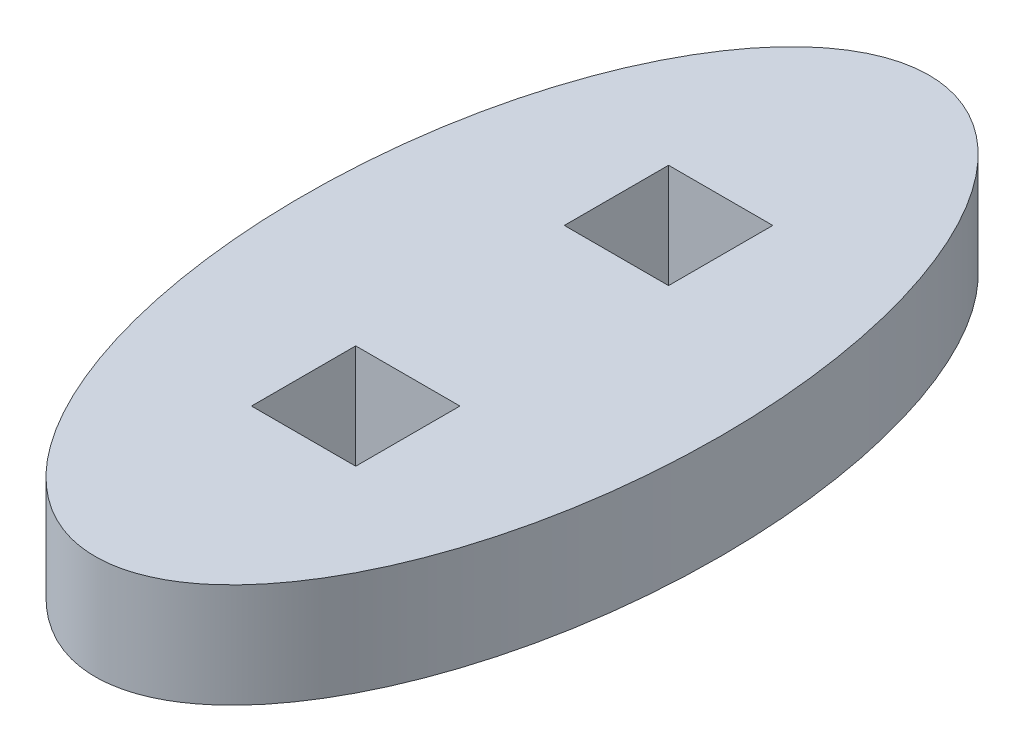
from build123d import *

# Parameters (mm, degrees)
SKETCH1_RX          = 12.7
SKETCH1_RY          = 6.35
BOSS_EXTRUDE1_DEPTH = 3.175
SKETCH2_W           = 3.175
SKETCH2_H           = 3.175
CUT_EXTRUDE1_DEPTH  = 4.175


with BuildPart() as part:
    # Sketch1 → Boss-Extrude1 (new body)
    with BuildSketch(Plane(origin=(0, 0, 0), x_dir=(1, 0, 0), z_dir=(0, 1, 0))):
        with Locations(Location((0, 0), (0, 0, 90))):
            Ellipse(SKETCH1_RX, SKETCH1_RY)
    extrude(amount=BOSS_EXTRUDE1_DEPTH)

    # Sketch2 → Cut-Extrude1 (cut, through all)
    with BuildSketch(Plane(origin=(0, 3.175, 0), x_dir=(1, 0, 0), z_dir=(0, 1, 0))):
        with Locations((0, 4.7675)):
            Rectangle(SKETCH2_W, SKETCH2_H)
        with Locations((0, -4.7625)):
            Rectangle(SKETCH2_W, SKETCH2_H)
    extrude(amount=-CUT_EXTRUDE1_DEPTH, mode=Mode.SUBTRACT)


solid = part.part
